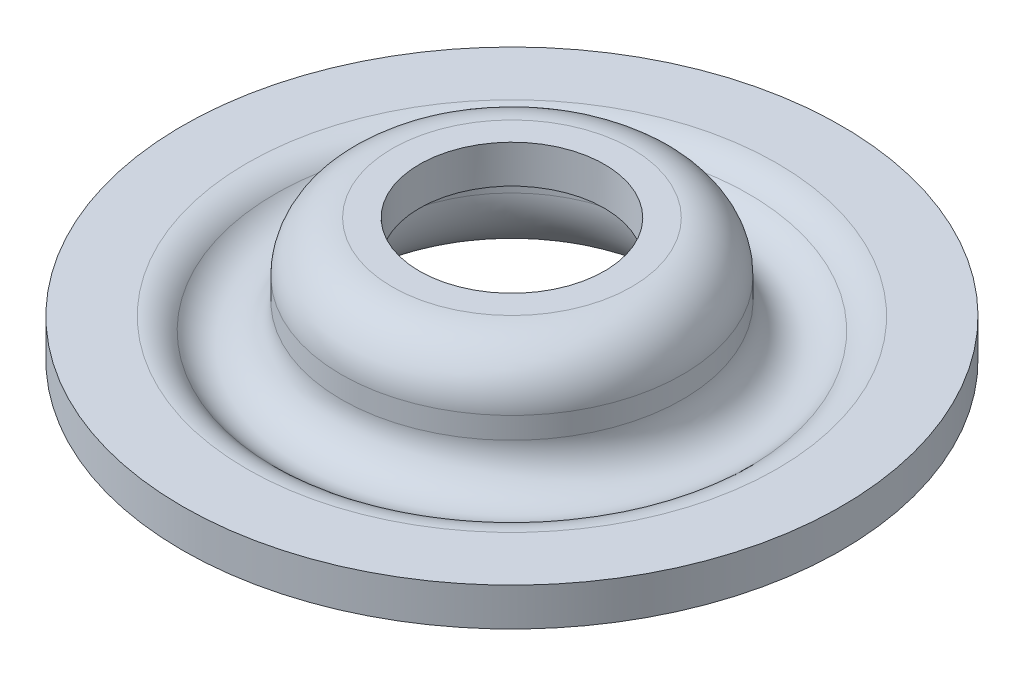
from build123d import *

# Parameters (mm, degrees)
FILLET1_R          = 3
SKETCH2_R          = 7.3
CUT_EXTRUDE1_DEPTH = 39.585531184


with BuildPart() as part:
    # Sketch1 → Revolve1 (revolve)
    with BuildSketch(Plane.XY):
        with BuildLine():
            Line((-26, 4.978), (-19.270552428, 4.978))
            ThreePointArc((-19.270552428, 4.978), (-15.931182732, 3.045202436), (-13.45, 6))
            Line((-13.45, 6), (-13.45, 7.698))
            ThreePointArc((-13.45, 7.698), (-12.278427125, 10.526427125), (-9.45, 11.698))
            Line((-9.45, 11.698), (0, 11.698))
            Line((0, 11.698), (0, 8.698))
            Line((0, 8.698), (-9.45, 8.698))
            ThreePointArc((-9.45, 8.698), (-10.157106781, 8.405106781), (-10.45, 7.698))
            Line((-10.45, 7.698), (-10.45, 6))
            ThreePointArc((-10.45, 6), (-14.295256898, 0.400260527), (-20.902360722, 1.978))
            Line((-20.902360722, 1.978), (-26, 1.978))
            Line((-26, 1.978), (-26, 4.978))
        make_face()
    revolve(axis=Axis((0, 55, 0), (0, -1, 0)))

    # Fillet1
    fillet1_edges = [part.edges().sort_by_distance(p)[0] for p in [
        (19.270552428, 4.978, 0),
    ]]
    fillet(fillet1_edges, radius=FILLET1_R)

    # Sketch2 → Cut-Extrude1 (cut, through all)
    with BuildSketch(Plane(origin=(0, 11.698, 0), x_dir=(1, 0, 0), z_dir=(0, 1, 0))):
        Circle(SKETCH2_R)
    extrude(amount=-CUT_EXTRUDE1_DEPTH, mode=Mode.SUBTRACT)


solid = part.part
